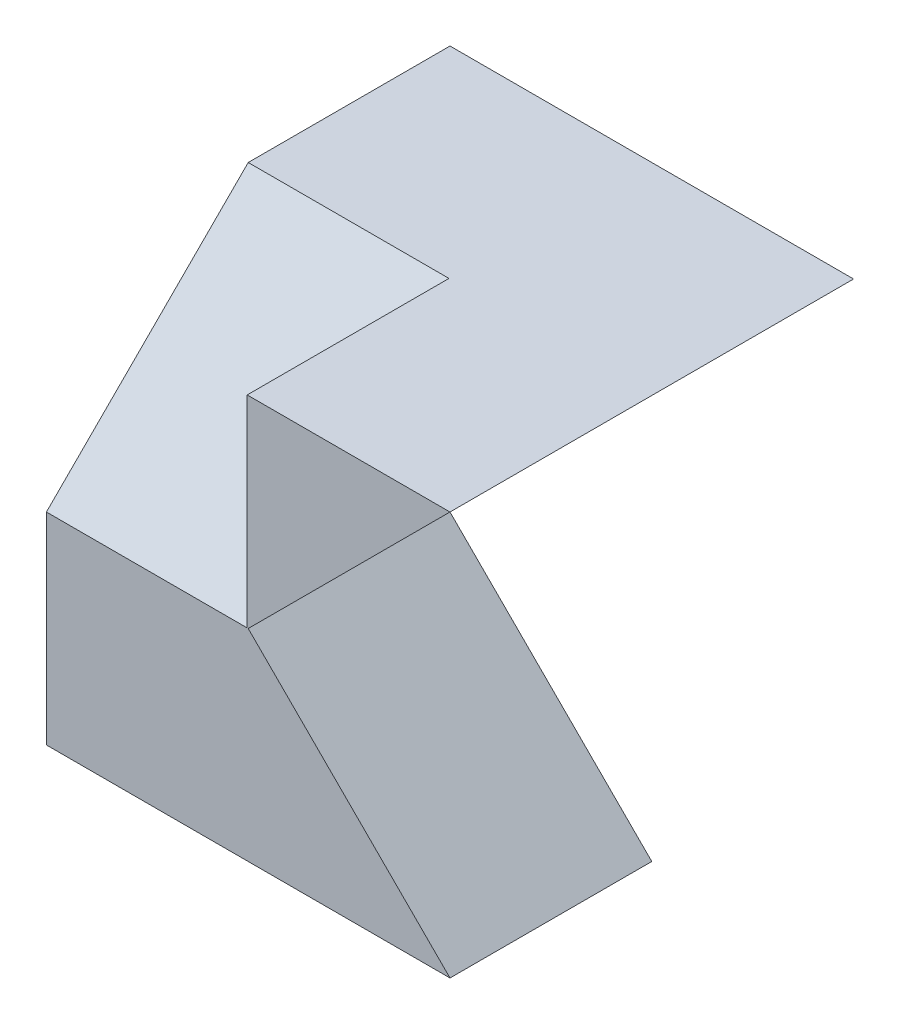
from build123d import *

# Parameters (mm, degrees)
SKETCH1_W           = 4
SKETCH1_H           = 4
BOSS_EXTRUDE1_DEPTH = 4
CUT_EXTRUDE1_DEPTH  = 4
CUT_EXTRUDE7_DEPTH  = 1.99
SKETCH6_W           = 2
SKETCH6_H           = 2
CUT_EXTRUDE8_DEPTH  = 21.99


with BuildPart() as part:
    # Sketch1 → Boss-Extrude1 (new body)
    with BuildSketch(Plane.XY):
        with Locations((2, 2)):
            Rectangle(SKETCH1_W, SKETCH1_H)
    extrude(amount=BOSS_EXTRUDE1_DEPTH)

    # Sketch2 → Cut-Extrude1 (cut)
    with BuildSketch(Plane.XY.offset(4)):
        Polygon((4, 4), (2, 2), (4, 0), align=None)
    extrude(amount=-CUT_EXTRUDE1_DEPTH, mode=Mode.SUBTRACT)

    # Sketch5 → Cut-Extrude7 (cut)
    with BuildSketch(Plane.ZY):
        Polygon((2, 4), (4, 2), (4, 4), align=None)
    extrude(amount=-CUT_EXTRUDE7_DEPTH, mode=Mode.SUBTRACT)

    # Sketch6 → Cut-Extrude8 (cut)
    with BuildSketch(Plane.ZY):
        with Locations((1, 1)):
            Rectangle(SKETCH6_W, SKETCH6_H)
    extrude(amount=-CUT_EXTRUDE8_DEPTH, mode=Mode.SUBTRACT)


solid = part.part
